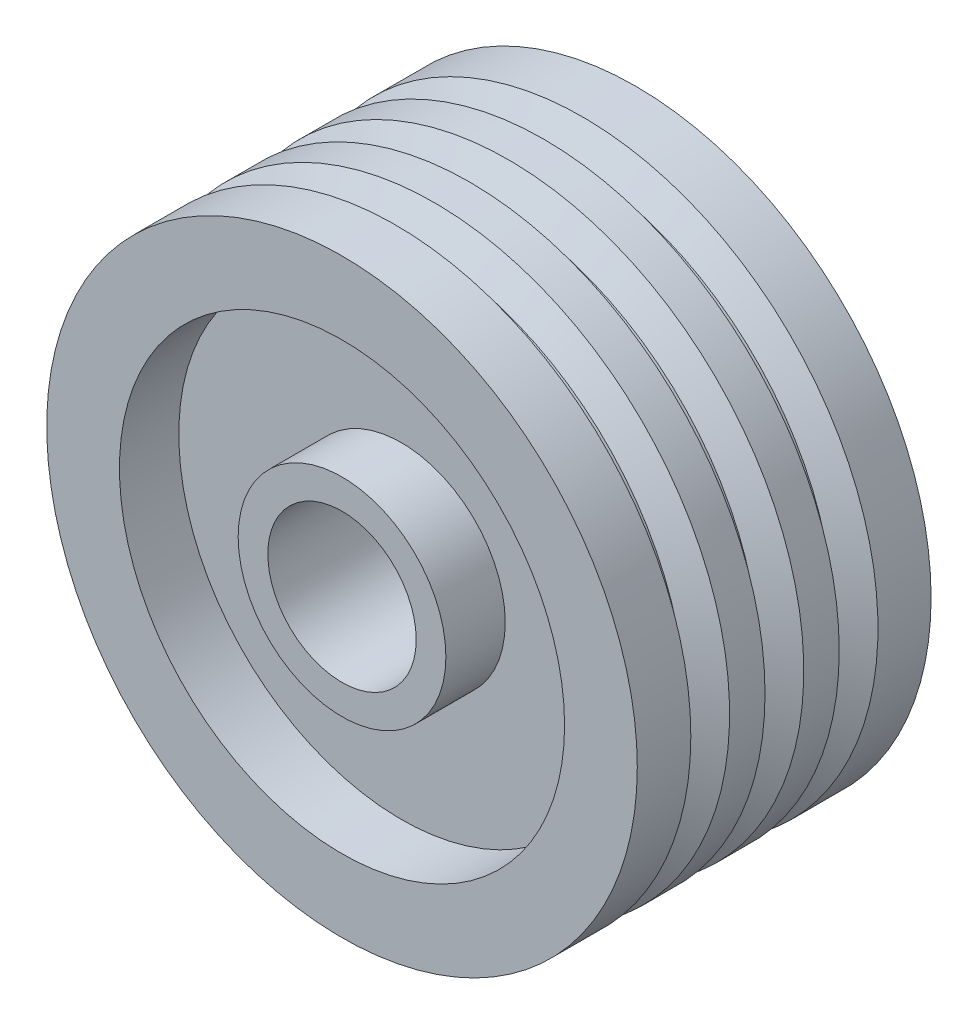
from build123d import *

# Parameters (mm, degrees)
SKETCH1_R               = 99.5
BOSS_EXTRUDE1_DEPTH     = 49.5
SKETCH3_R               = 75
SKETCH3_R_2             = 35
CUT_EXTRUDE1_DEPTH      = 20
SKETCH4_R               = 25
CUT_EXTRUDE2_DEPTH      = 1.0000001
CUT_EXTRUDE2_DEPTH_BACK = 100.0000001
SKETCH5_R               = 75
SKETCH5_R_2             = 35
CUT_EXTRUDE3_DEPTH      = 20


with BuildPart() as part:
    # Sketch1 → Boss-Extrude1 (new body, symmetric)
    with BuildSketch(Plane.XY):
        Circle(SKETCH1_R)
    extrude(amount=BOSS_EXTRUDE1_DEPTH, both=True)

    # Sketch2 → Cut-Revolve1 (revolve, cut)
    with BuildSketch(Plane(origin=(0, 0, 0), x_dir=(1, 0, 0), z_dir=(0, 1, 0))):
        Polygon((-89.981945933, -25.982850646), (-99.911722122, -31.694962561), (-99.915568006, -18.158689934), (-90.018054068, -23.893839429), align=None)
        Polygon((-89.981945933, -0.982850646), (-99.911722122, -6.694962562), (-99.92977619, 6.849543049), (-90.018054068, 1.106160571), align=None)
        Polygon((-90.016592149, 23.99721909), (-99.911722122, 18.305037438), (-99.92977619, 31.849543049), (-90.018054068, 26.106160571), align=None)
    revolve(axis=Axis((0, 0, 0), (0, 0, 1)), mode=Mode.SUBTRACT)

    # Sketch3 → Cut-Extrude1 (cut)
    with BuildSketch(Plane(origin=(0, 0, -49.5), x_dir=(-1, 0, 0), z_dir=(0, 0, -1))):
        Circle(SKETCH3_R)
        Circle(SKETCH3_R_2, mode=Mode.SUBTRACT)
    extrude(amount=-CUT_EXTRUDE1_DEPTH, mode=Mode.SUBTRACT)

    # Sketch4 → Cut-Extrude2 (cut, two sides)
    with BuildSketch(Plane.XY.offset(49.5)) as cut_extrude2_sk:
        Circle(SKETCH4_R)
    extrude(amount=CUT_EXTRUDE2_DEPTH, mode=Mode.SUBTRACT)
    extrude(cut_extrude2_sk.sketch, amount=-CUT_EXTRUDE2_DEPTH_BACK, mode=Mode.SUBTRACT)

    # Sketch5 → Cut-Extrude3 (cut)
    with BuildSketch(Plane.XY.offset(49.5)):
        Circle(SKETCH5_R)
        Circle(SKETCH5_R_2, mode=Mode.SUBTRACT)
    extrude(amount=-CUT_EXTRUDE3_DEPTH, mode=Mode.SUBTRACT)


solid = part.part
